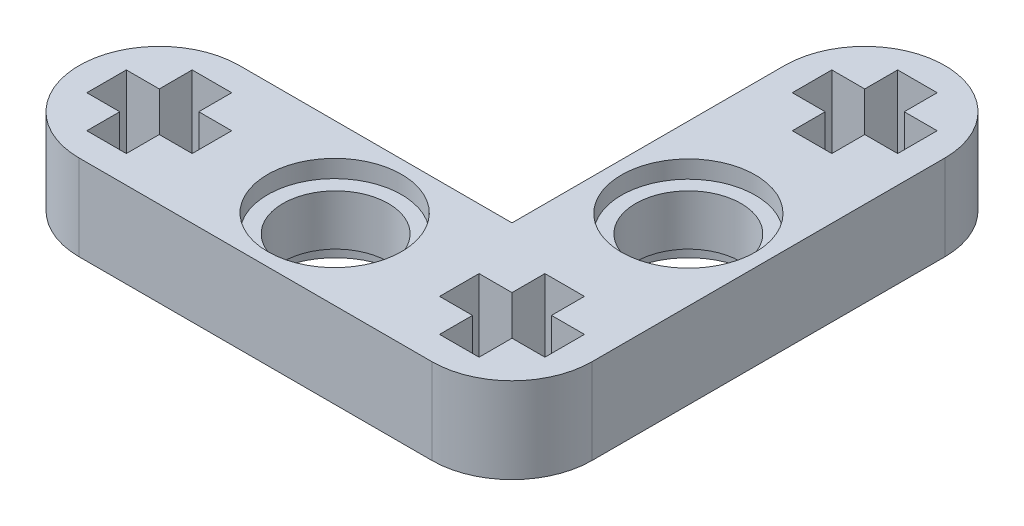
from build123d import *

# Parameters (mm, degrees)
SKETCH1_R           = 2.4
BOSS_EXTRUDE1_DEPTH = 3.9
SKETCH2_R           = 3.05
CUT_EXTRUDE1_DEPTH  = 0.8
SKETCH3_R           = 3.05
CUT_EXTRUDE2_DEPTH  = 0.8


with BuildPart() as part:
    # Sketch1 → Boss-Extrude1 (new body)
    with BuildSketch(Plane(origin=(0, 0, 0), x_dir=(1, 0, 0), z_dir=(0, 1, 0))):
        with BuildLine():
            Line((-7.989922998, 3.65), (4.430077002, 3.65))
            Line((4.430077002, 3.65), (4.430077002, 16.07))
            ThreePointArc((4.430077002, 16.07), (8.080077002, 19.72), (11.730077002, 16.07))
            Line((11.730077002, 16.07), (11.730077002, 0))
            ThreePointArc((11.730077002, 0), (10.661016754, -2.580939751), (8.080077002, -3.65))
            Line((8.080077002, -3.65), (-7.989922998, -3.65))
            ThreePointArc((-7.989922998, -3.65), (-11.639922998, 0), (-7.989922998, 3.65))
        make_face()
        with Locations((0.045077002, 0)):
            Circle(SKETCH1_R, mode=Mode.SUBTRACT)
        with Locations((8.080077002, 8.035)):
            Circle(SKETCH1_R, mode=Mode.SUBTRACT)
        Polygon((8.980077002, 16.97), (10.480077002, 16.97), (10.480077002, 15.17), (8.980077002, 15.17), (8.980077002, 13.67), (7.180077002, 13.67), (7.180077002, 15.17), (5.680077002, 15.17), (5.680077002, 16.97), (7.180077002, 16.97), (7.180077002, 18.47), (8.980077002, 18.47), align=None, mode=Mode.SUBTRACT)
        Polygon((-8.889922998, -2.4), (-7.089922998, -2.4), (-7.089922998, -0.9), (-5.589922998, -0.9), (-5.589922998, 0.9), (-7.089922998, 0.9), (-7.089922998, 2.4), (-8.889922998, 2.4), (-8.889922998, 0.9), (-10.389922998, 0.9), (-10.389922998, -0.9), (-8.889922998, -0.9), align=None, mode=Mode.SUBTRACT)
        Polygon((7.180077002, -2.4), (8.980077002, -2.4), (8.980077002, -0.9), (10.480077002, -0.9), (10.480077002, 0.9), (8.980077002, 0.9), (8.980077002, 2.4), (7.180077002, 2.4), (7.180077002, 0.9), (5.680077002, 0.9), (5.680077002, -0.9), (7.180077002, -0.9), align=None, mode=Mode.SUBTRACT)
    extrude(amount=BOSS_EXTRUDE1_DEPTH)

    # Sketch2 → Cut-Extrude1 (cut)
    with BuildSketch(Plane(origin=(0, 3.9, 0), x_dir=(1, 0, 0), z_dir=(0, 1, 0))):
        Circle(SKETCH2_R)
        with Locations((8.080077002, 8.035)):
            Circle(SKETCH2_R)
    extrude(amount=-CUT_EXTRUDE1_DEPTH, mode=Mode.SUBTRACT)

    # Sketch3 → Cut-Extrude2 (cut)
    with BuildSketch(Plane.XZ):
        with Locations((8.080077002, -8.035)):
            Circle(SKETCH3_R)
        with Locations((0.045077002, 0)):
            Circle(SKETCH3_R)
    extrude(amount=-CUT_EXTRUDE2_DEPTH, mode=Mode.SUBTRACT)


solid = part.part
